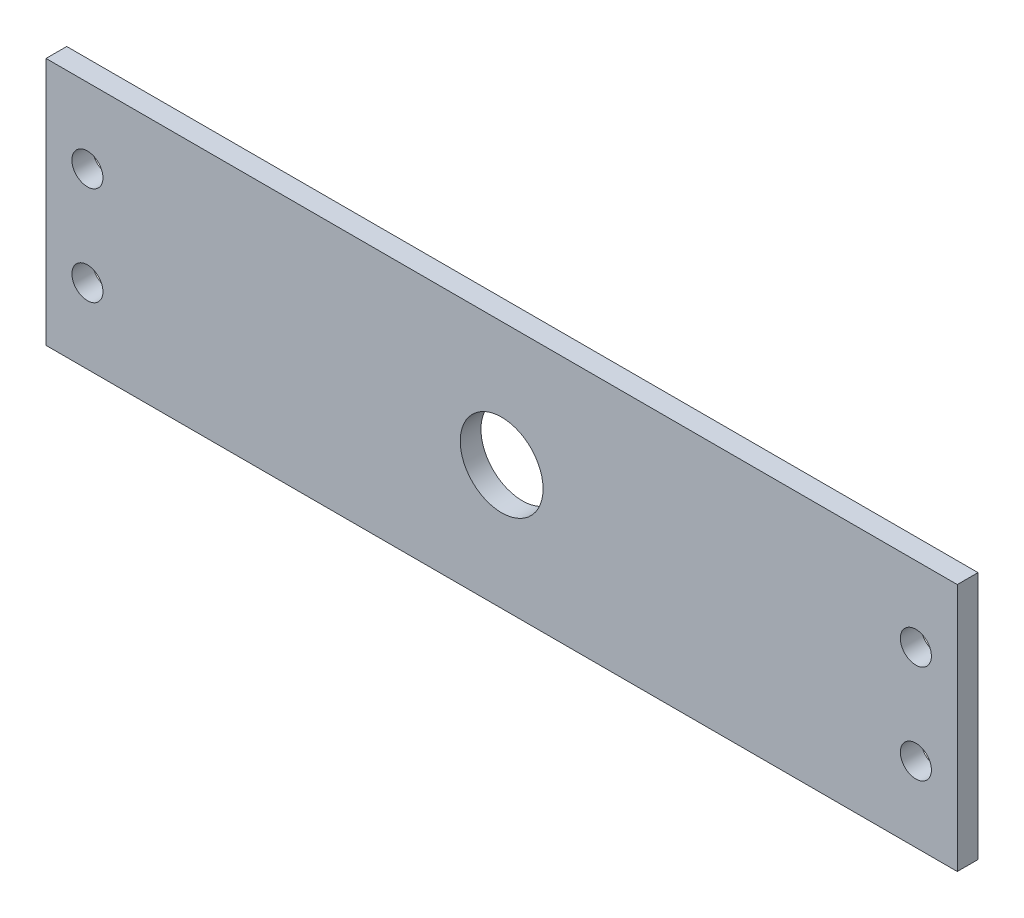
from build123d import *

# Parameters (mm, degrees)
SKETCH1_W           = 558.8
SKETCH1_H           = 152.4
BOSS_EXTRUDE1_DEPTH = 12.7
SKETCH2_R           = 9.525
SKETCH2_R_2         = 25.4
CUT_EXTRUDE1_DEPTH  = 13.7


with BuildPart() as part:
    # Sketch1 → Boss-Extrude1 (new body)
    with BuildSketch(Plane.XY):
        with Locations((279.4, 76.2)):
            Rectangle(SKETCH1_W, SKETCH1_H)
    extrude(amount=BOSS_EXTRUDE1_DEPTH)

    # Sketch2 → Cut-Extrude1 (cut, through all)
    with BuildSketch(Plane.XY.offset(12.7)):
        with Locations((533.4, 45.974)):
            Circle(SKETCH2_R)
        with Locations((533.4, 106.426)):
            Circle(SKETCH2_R)
        with Locations((25.4, 45.974)):
            Circle(SKETCH2_R)
        with Locations((25.4, 106.426)):
            Circle(SKETCH2_R)
        with Locations((279.4, 76.2)):
            Circle(SKETCH2_R_2)
    extrude(amount=-CUT_EXTRUDE1_DEPTH, mode=Mode.SUBTRACT)


solid = part.part
